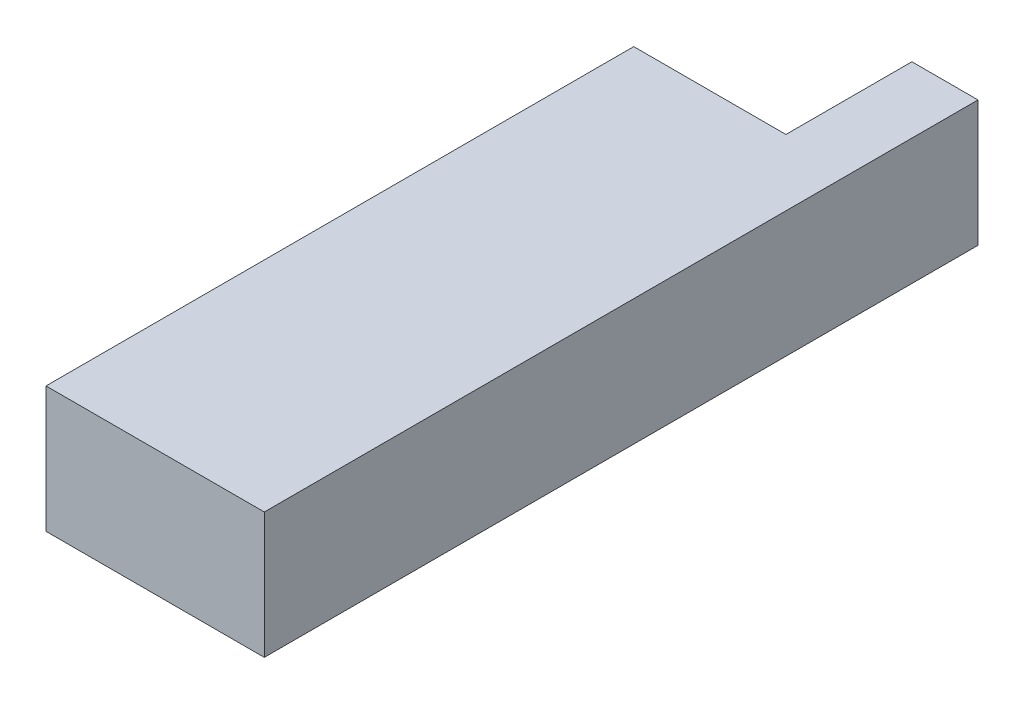
from build123d import *

# Parameters (mm, degrees)
SKETCH1_W           = 33.02
SKETCH1_H           = 88.9
BOSS_EXTRUDE1_DEPTH = 9.525
SKETCH2_W           = 10
SKETCH2_H           = 19.05
BOSS_EXTRUDE2_DEPTH = 19.05


with BuildPart() as part:
    # Sketch1 → Boss-Extrude1 (new body, symmetric)
    with BuildSketch(Plane(origin=(0, 0, 0), x_dir=(1, 0, 0), z_dir=(0, 1, 0))):
        Rectangle(SKETCH1_W, SKETCH1_H)
    extrude(amount=BOSS_EXTRUDE1_DEPTH, both=True)

    # Sketch2 → Boss-Extrude2 (add)
    with BuildSketch(Plane(origin=(0, 0, -44.45), x_dir=(-1, 0, 0), z_dir=(0, 0, -1))):
        with Locations((-11.51, 0)):
            Rectangle(SKETCH2_W, SKETCH2_H)
    extrude(amount=BOSS_EXTRUDE2_DEPTH)


solid = part.part
